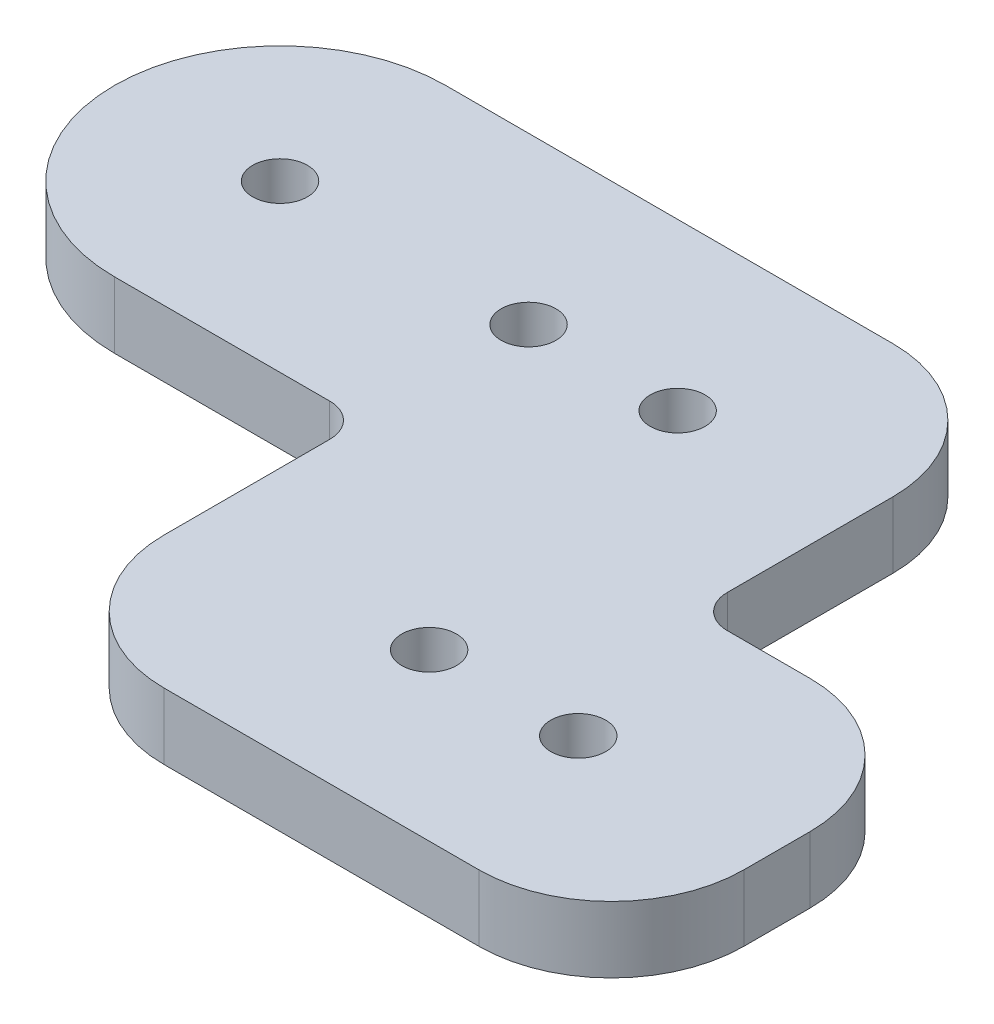
from build123d import *

# Parameters (mm, degrees)
SKETCH1_R           = 2.1
BOSS_EXTRUDE1_DEPTH = 5.08
FILLET1_R           = 2.54
FILLET2_R           = 10.16


with BuildPart() as part:
    # Sketch1 → Boss-Extrude1 (new body)
    with BuildSketch(Plane(origin=(0, 0, 0), x_dir=(1, 0, 0), z_dir=(0, 1, 0))):
        with BuildLine():
            ThreePointArc((0, 12.7), (-12.7, 0), (0, -12.7))
            Line((0, -12.7), (19.05, -12.7))
            Line((19.05, -12.7), (19.05, -38.1))
            Line((19.05, -38.1), (35.56, -38.1))
            Line((35.56, -38.1), (63.5, -38.1))
            Line((63.5, -38.1), (63.5, -12.7))
            Line((63.5, -12.7), (44.45, -12.7))
            Line((44.45, -12.7), (44.45, 12.7))
            Line((44.45, 12.7), (22.225, 12.7))
            Line((22.225, 12.7), (0, 12.7))
        make_face()
        with Locations((36.83, -25.4)):
            Circle(SKETCH1_R, mode=Mode.SUBTRACT)
        with Locations((48.26, -25.4)):
            Circle(SKETCH1_R, mode=Mode.SUBTRACT)
        Circle(SKETCH1_R, mode=Mode.SUBTRACT)
        with Locations((19.05, 0)):
            Circle(SKETCH1_R, mode=Mode.SUBTRACT)
        with Locations((30.48, 0)):
            Circle(SKETCH1_R, mode=Mode.SUBTRACT)
    extrude(amount=BOSS_EXTRUDE1_DEPTH)

    # Fillet1
    fillet1_edges = [part.edges().sort_by_distance(p)[0] for p in [
        (44.45, 2.54, 12.7),
        (19.05, 2.54, 12.7),
    ]]
    fillet(fillet1_edges, radius=FILLET1_R)

    # Fillet2
    fillet2_edges = [part.edges().sort_by_distance(p)[0] for p in [
        (44.45, 2.54, -12.7),
        (63.5, 2.54, 12.7),
        (63.5, 2.54, 38.1),
        (19.05, 2.54, 38.1),
    ]]
    fillet(fillet2_edges, radius=FILLET2_R)


solid = part.part
